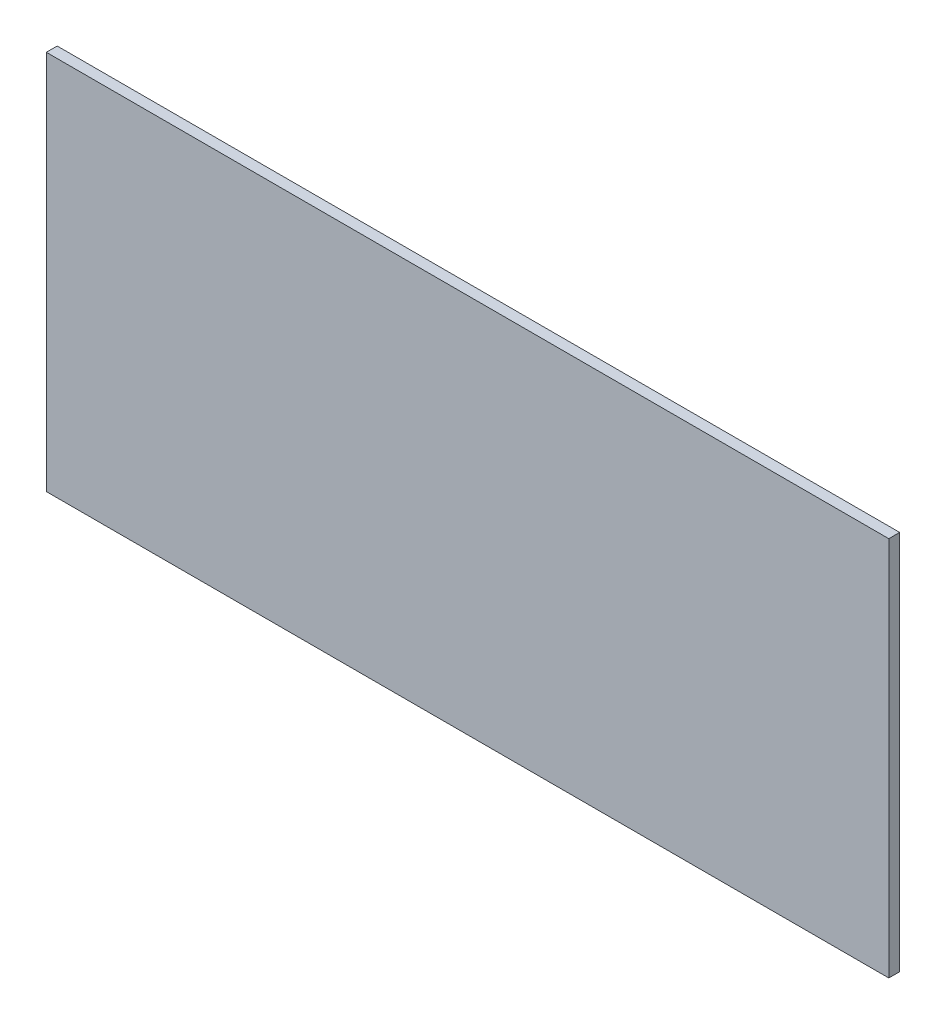
from build123d import *

# Parameters (mm, degrees)
SKETCH2_W           = 155
SKETCH2_H           = 70
BOSS_EXTRUDE1_DEPTH = 2


with BuildPart() as part:
    # Sketch2 → Boss-Extrude1 (new body)
    with BuildSketch(Plane.XY):
        Rectangle(SKETCH2_W, SKETCH2_H)
    extrude(amount=BOSS_EXTRUDE1_DEPTH)


solid = part.part
